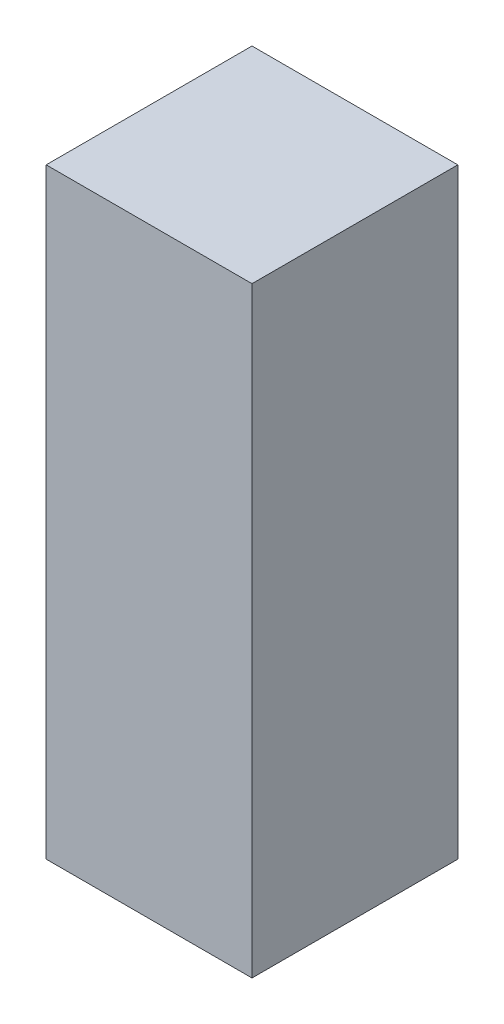
from build123d import *

# Parameters (mm, degrees)
SKETCH1_W           = 51
SKETCH1_H           = 51
BOSS_EXTRUDE1_DEPTH = 149


with BuildPart() as part:
    # Sketch1 → Boss-Extrude1 (new body)
    with BuildSketch(Plane(origin=(0, 0, 0), x_dir=(1, 0, 0), z_dir=(0, 1, 0))):
        Rectangle(SKETCH1_W, SKETCH1_H)
    extrude(amount=BOSS_EXTRUDE1_DEPTH)

    # Sketch2 → Cut-Revolve1 (revolve, cut)
    with BuildSketch(Plane.XY):
        with BuildLine():
            ThreePointArc((4.274651913, 62.011311077), (12.488688923, 78.774651913), (-4.274651913, 86.988688923))
            Line((-4.274651913, 86.988688923), (4.274651913, 62.011311077))
        make_face()
    revolve(axis=Axis((-25.5, 149, 0), (0.32383726615945974, -0.9461127972109706, 0)), mode=Mode.SUBTRACT)


with BuildPart() as body_2:
    # Sketch2_4 → Revolve2 (revolve)
    with BuildSketch(Plane.XY):
        with BuildLine():
            Line((-4.274651913, 86.988688923), (4.274651913, 62.011311077))
            ThreePointArc((4.274651913, 62.011311077), (12.488688923, 78.774651913), (-4.274651913, 86.988688923))
        make_face()
    revolve(axis=Axis((-25.5, 149, 0), (0.32383726615945974, -0.9461127972109706, 0)))


solid = Compound([part.part, body_2.part])
